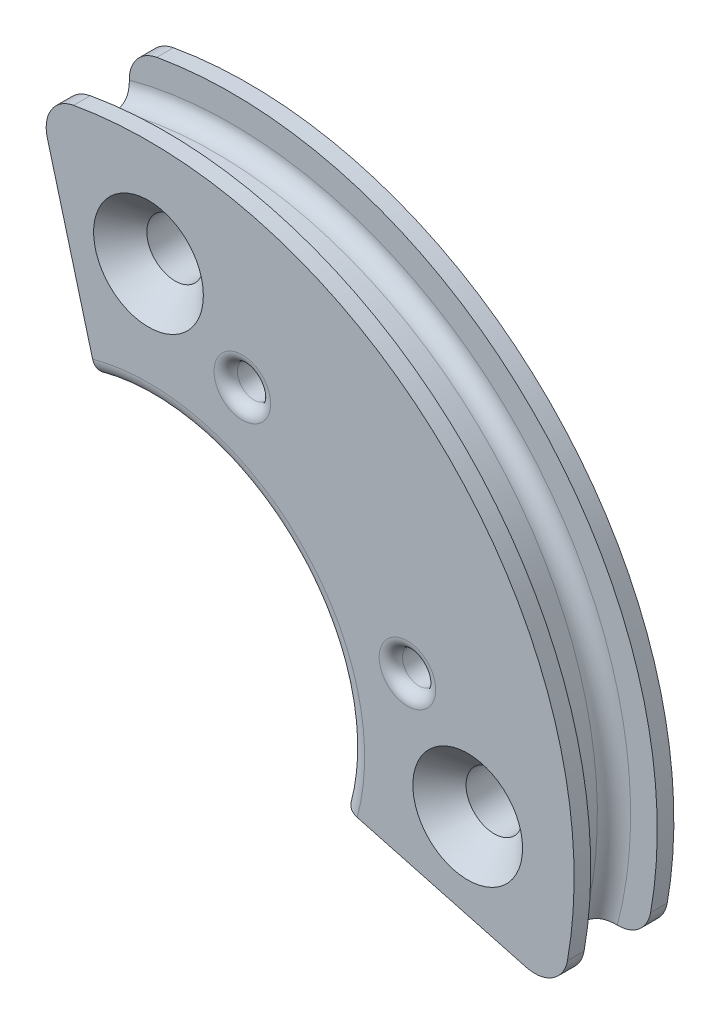
from build123d import *

# Parameters (mm, degrees)
SKETCH1_R               = 12
SKETCH1_R_2             = 0.85
SKETCH1_R_3             = 6
BOSS_EXTRUDE1_DEPTH     = 1.5
SKETCH6_W               = 0.8
SKETCH6_H               = 0.5
CUT_EXTRUDE1_DEPTH      = 2.5
CUT_EXTRUDE1_DEPTH_BACK = 2.5
SKETCH5_R               = 0.5
CUT_EXTRUDE2_DEPTH      = 1
CUT_EXTRUDE2_DEPTH_BACK = 4
FILLET1_R               = 0.5
FILLET2_R               = 1
CHAMFER1_SIZE           = 0.8
FILLET3_R               = 0.35
FILLET4_R               = 0.35


with BuildPart() as part:
    # Sketch1 → Boss-Extrude1 (new body, symmetric)
    with BuildSketch(Plane.XY):
        Circle(SKETCH1_R)
        with Locations((9.6, 0)):
            Circle(SKETCH1_R_2, mode=Mode.SUBTRACT)
        Circle(SKETCH1_R_3, mode=Mode.SUBTRACT)
        with Locations((0, -9.6)):
            Circle(SKETCH1_R_2, mode=Mode.SUBTRACT)
        with Locations((-9.6, 0)):
            Circle(SKETCH1_R_2, mode=Mode.SUBTRACT)
        with Locations((0, 9.6)):
            Circle(SKETCH1_R_2, mode=Mode.SUBTRACT)
    extrude(amount=BOSS_EXTRUDE1_DEPTH, both=True)

    # Sketch2 → Cut-Revolve1 (revolve, cut)
    with BuildSketch(Plane(origin=(0, 0, 0), x_dir=(1, 0, 0), z_dir=(0, 1, 0))):
        with BuildLine():
            Line((-11.5, 0.5), (-11.5, -0.5))
            ThreePointArc((-11.5, -0.5), (-11.646446609, -0.853553391), (-12, -1))
            Line((-12, -1), (-12, 1))
            ThreePointArc((-12, 1), (-11.646446609, 0.853553391), (-11.5, 0.5))
        make_face()
    revolve(axis=Axis((0, 0, 0), (0, 0, -1)), mode=Mode.SUBTRACT)

    # Sketch6 → Revolve1 (revolve)
    with BuildSketch(Plane(origin=(0, 0, 0), x_dir=(1, 0, 0), z_dir=(0, 1, 0))):
        with Locations((12.4, 1.25)):
            Rectangle(SKETCH6_W, SKETCH6_H)
        with Locations((12.4, -1.25)):
            Rectangle(SKETCH6_W, SKETCH6_H)
    revolve(axis=Axis((0, 0, 0), (0, 0, -1)))

    # Sketch4 → Cut-Extrude1 (cut, two sides)
    with BuildSketch(Plane.XY) as cut_extrude1_sk:
        Polygon((-3.743635752, 13.97143883), (0, 0), (14.900233226, -3.99250546), (14.900233226, -14.839385646), (-15.188066433, -14.839385646), (-15.188066433, 13.97143883), align=None)
    extrude(amount=CUT_EXTRUDE1_DEPTH, mode=Mode.SUBTRACT)
    extrude(cut_extrude1_sk.sketch, amount=-CUT_EXTRUDE1_DEPTH_BACK, mode=Mode.SUBTRACT)

    # Sketch5 → Cut-Extrude2 (cut, two sides)
    with BuildSketch(Plane.XY.offset(1.5)) as cut_extrude2_sk:
        with Locations((2.82143232, 7.787460269)):
            Circle(SKETCH5_R)
        with Locations((7.787460269, 2.82143232)):
            Circle(SKETCH5_R)
    extrude(amount=CUT_EXTRUDE2_DEPTH, mode=Mode.SUBTRACT)
    extrude(cut_extrude2_sk.sketch, amount=-CUT_EXTRUDE2_DEPTH_BACK, mode=Mode.SUBTRACT)

    # Fillet1
    fillet1_edges = [part.edges().sort_by_distance(p)[0] for p in [
        (4.242640687, 4.242640687, 1.5),
        (4.242640687, 4.242640687, -1.5),
    ]]
    fillet(fillet1_edges, radius=FILLET1_R)

    # Fillet2
    fillet2_edges = [part.edges().sort_by_distance(p)[0] for p in [
        (12.363850577, -3.312883777, -1.25),
        (12.363850577, -3.312883777, 1.25),
        (-3.312883777, 12.363850577, -1.25),
        (-3.312883777, 12.363850577, 1.25),
    ]]
    fillet(fillet2_edges, radius=FILLET2_R)

    # Chamfer1
    chamfer1_edges = [part.edges().sort_by_distance(p)[0] for p in [
        (8.75, 0, 1.5),
        (-0.85, 9.6, 1.5),
    ]]
    chamfer(chamfer1_edges, length=CHAMFER1_SIZE)

    # Fillet3
    fillet3_edges = [part.edges().sort_by_distance(p)[0] for p in [
        (2.32143232, 7.787460269, 1.5),
        (7.287460269, 2.82143232, 1.5),
    ]]
    fillet(fillet3_edges, radius=FILLET3_R)

    # Fillet4
    fillet4_edges = [part.edges().sort_by_distance(p)[0] for p in [
        (2.32143232, 7.787460269, -1.5),
        (7.287460269, 2.82143232, -1.5),
    ]]
    fillet(fillet4_edges, radius=FILLET4_R)


solid = part.part
